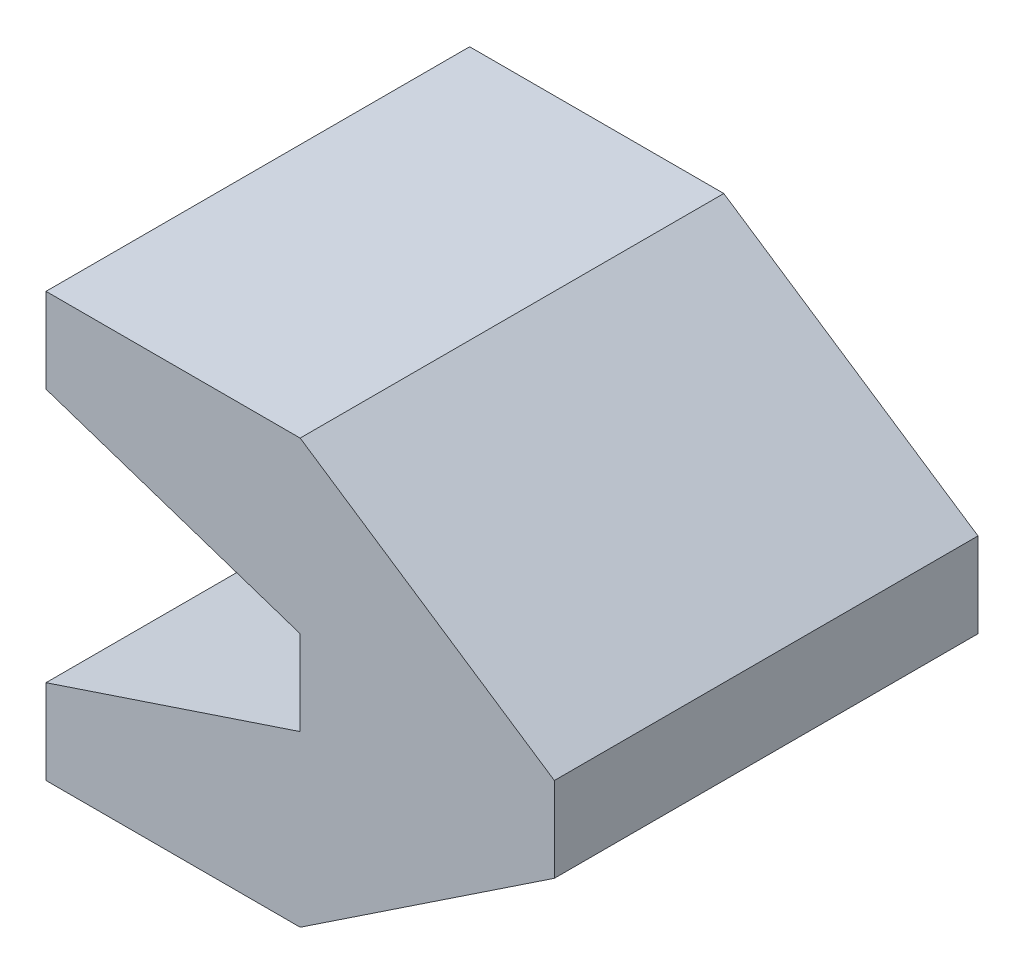
from build123d import *

# Parameters (mm, degrees)
BOSS_EXTRUDE1_DEPTH = 25


with BuildPart() as part:
    # Sketch1 → Boss-Extrude1 (new body)
    with BuildSketch(Plane.XY):
        Polygon((-15, 25), (0, 25), (15, 15), (15, 10), (0, 0), (-15, 0), (-15, 5), (0, 10), (0, 15), (-15, 20), align=None)
    extrude(amount=BOSS_EXTRUDE1_DEPTH)


solid = part.part
